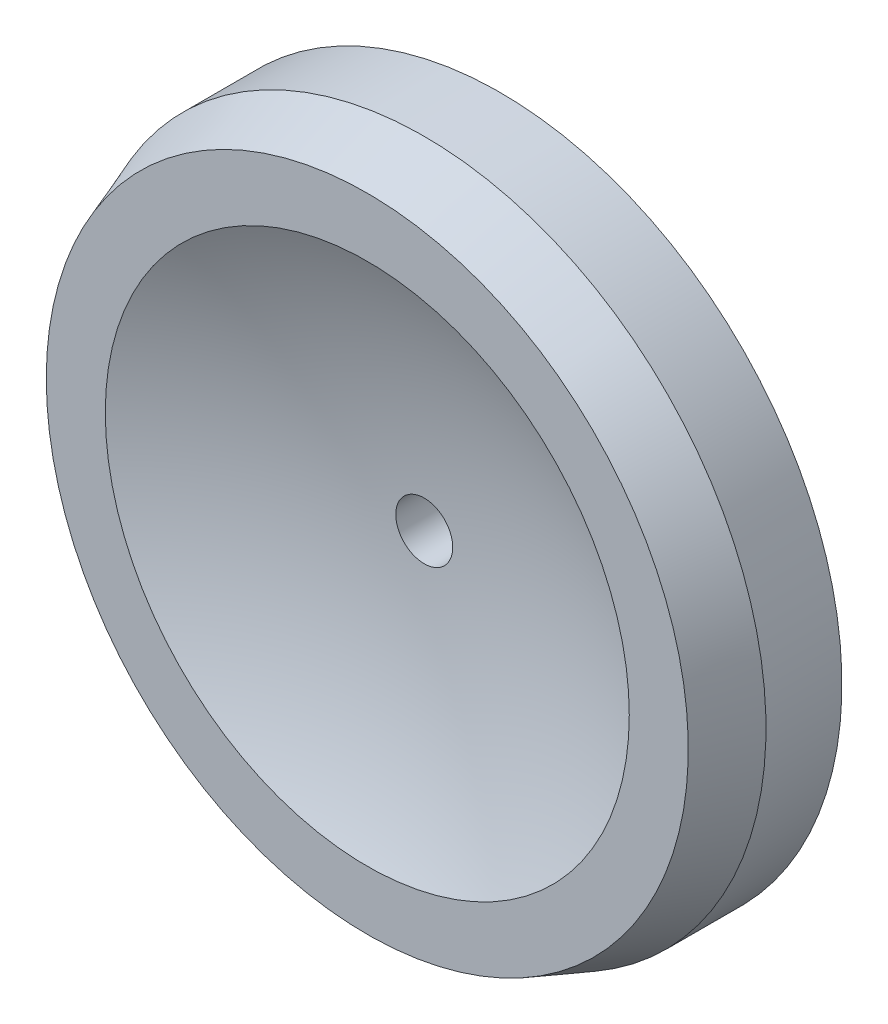
from build123d import *


with BuildPart() as part:
    # Sketch1 → Revolve1 (revolve)
    with BuildSketch(Plane.XZ.offset(10.646000252)):
        with BuildLine():
            Line((5.597017702, 1.52), (5.542422167, 1.67))
            Line((5.542422167, 1.67), (5.387017702, 1.67))
            ThreePointArc((5.387017702, 1.67), (5.086801296, 1.565137265), (4.772017702, 1.52))
            Line((4.772017702, 1.52), (4.772017702, 1.32))
            Line((4.772017702, 1.32), (5.597017702, 1.32))
            Line((5.597017702, 1.32), (5.597017702, 1.52))
        make_face()
    revolve(axis=Axis((4.697017702, -10.646000252, 1.67), (0, 0, -1)))


solid = part.part
